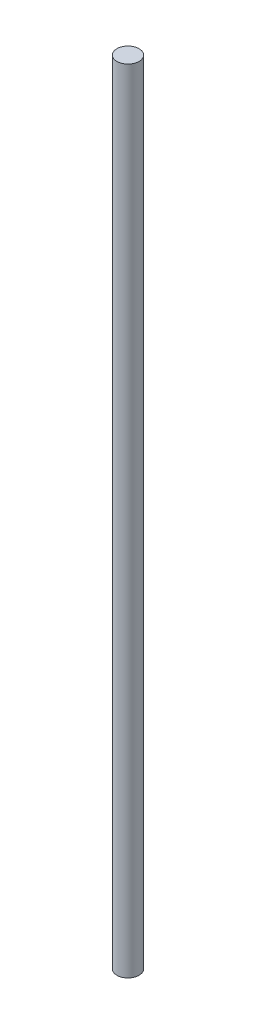
from build123d import *

# Parameters (mm, degrees)
SKETCH1_R           = 4
BOSS_EXTRUDE1_DEPTH = 286


with BuildPart() as part:
    # Sketch1 → Boss-Extrude1 (new body)
    with BuildSketch(Plane(origin=(0, 0, 0), x_dir=(1, 0, 0), z_dir=(0, 1, 0))):
        Circle(SKETCH1_R)
    extrude(amount=BOSS_EXTRUDE1_DEPTH)


solid = part.part
